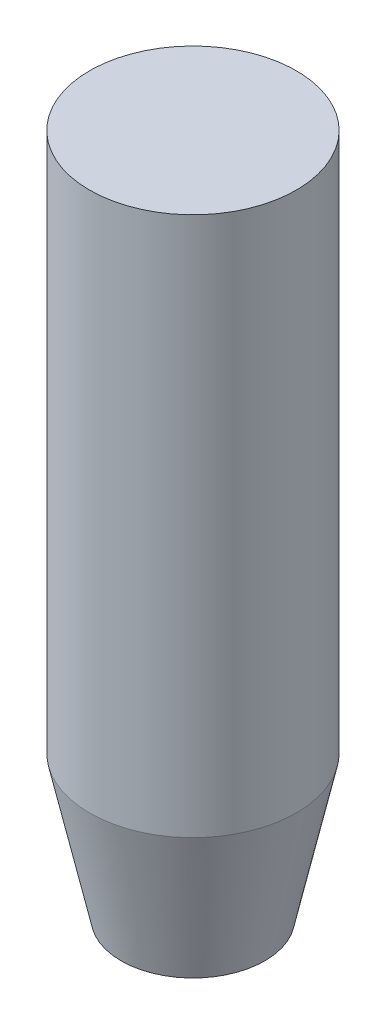
from build123d import *

# Parameters (mm, degrees)
SKETCH1_R           = 18.25625
BOSS_EXTRUDE1_DEPTH = 120.65
CHAMFER1_SIZE       = 5.55625
CHAMFER1_SIZE2      = 25.4


with BuildPart() as part:
    # Sketch1 → Boss-Extrude1 (new body)
    with BuildSketch(Plane(origin=(0, 0, 0), x_dir=(1, 0, 0), z_dir=(0, 1, 0))):
        Circle(SKETCH1_R)
    extrude(amount=BOSS_EXTRUDE1_DEPTH)

    # Chamfer1
    chamfer1_edges = [part.edges().sort_by_distance(p)[0] for p in [
        (-18.25625, 0, 0),
    ]]
    chamfer1_side = [part.faces().sort_by_distance(p)[0] for p in [
        (0, 0, 0),
    ]]
    chamfer(chamfer1_edges, length=CHAMFER1_SIZE, length2=CHAMFER1_SIZE2, reference=chamfer1_side[0])


solid = part.part
